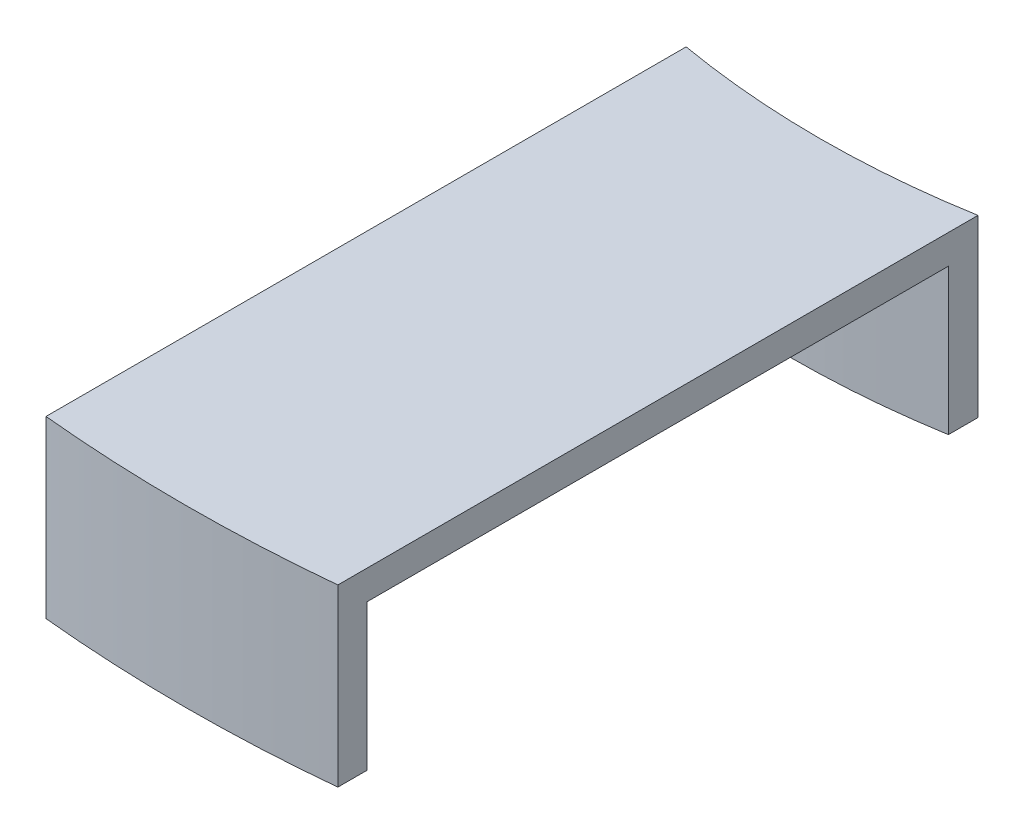
from build123d import *

# Parameters (mm, degrees)
BOSS_EXTRUDE1_DEPTH = 5
SHELL2_T            = 1


with BuildPart() as part:
    # Sketch1 → Boss-Extrude1 (new body)
    with BuildSketch(Plane(origin=(0, 0, 0), x_dir=(1, 0, 0), z_dir=(0, 1, 0))):
        with BuildLine():
            ThreePointArc((-5, -49.787563146), (0, -50.038), (5, -49.787563146))
            Line((5, -49.787563146), (5, -29.873965426))
            ThreePointArc((5, -29.873965426), (0, -30.2895), (-5, -29.873965426))
            Line((-5, -29.873965426), (-5, -49.787563146))
        make_face()
    extrude(amount=BOSS_EXTRUDE1_DEPTH)

    # Shell2
    shell2_openings = [part.faces().sort_by_distance(p)[0] for p in [
        (5, 2.5, 39.830764286),
        (-5, 2.5, 39.830764286),
        (0, 0, 40.052741683),
    ]]
    offset(amount=SHELL2_T, openings=shell2_openings, kind=Kind.INTERSECTION)


solid = part.part
